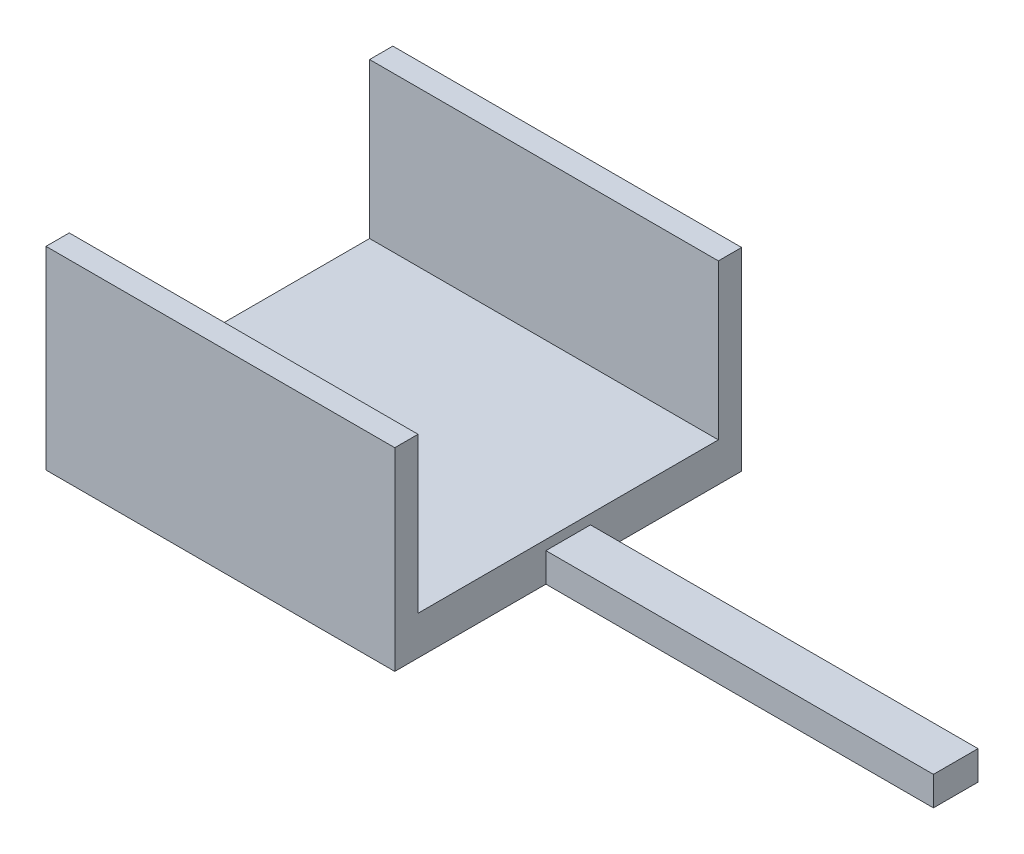
from build123d import *

# Parameters (mm, degrees)
EXTRUDE_1_DEPTH = 1.5
SKETCH_2_W      = 18
SKETCH_2_H      = 17.9
EXTRUDE_2_DEPTH = 0.5
SKETCH_3_W      = 18
SKETCH_3_H      = 1.2
EXTRUDE_3_DEPTH = 8


with BuildPart() as part:
    # 草图1 → 凸台-拉伸1 (new body)
    with BuildSketch(Plane(origin=(0, 0, 0), x_dir=(1, 0, 0), z_dir=(0, 1, 0))):
        Polygon((18, 10.1), (18, 17.9), (0, 17.9), (0, 0), (18, 0), (18, 7.8), (38, 7.8), (38, 10.1), align=None)
    extrude(amount=EXTRUDE_1_DEPTH)

    # 草图2 → 凸台-拉伸2 (add)
    with BuildSketch(Plane(origin=(0, 1.5, 0), x_dir=(1, 0, 0), z_dir=(0, 1, 0))):
        with Locations((9, 8.95)):
            Rectangle(SKETCH_2_W, SKETCH_2_H)
    extrude(amount=EXTRUDE_2_DEPTH)

    # 草图3 → 凸台-拉伸3 (add)
    with BuildSketch(Plane(origin=(0, 2, 0), x_dir=(1, 0, 0), z_dir=(0, 1, 0))):
        with Locations((9, 17.3)):
            Rectangle(SKETCH_3_W, SKETCH_3_H)
        with Locations((9, 0.6)):
            Rectangle(SKETCH_3_W, SKETCH_3_H)
    extrude(amount=EXTRUDE_3_DEPTH)


solid = part.part
